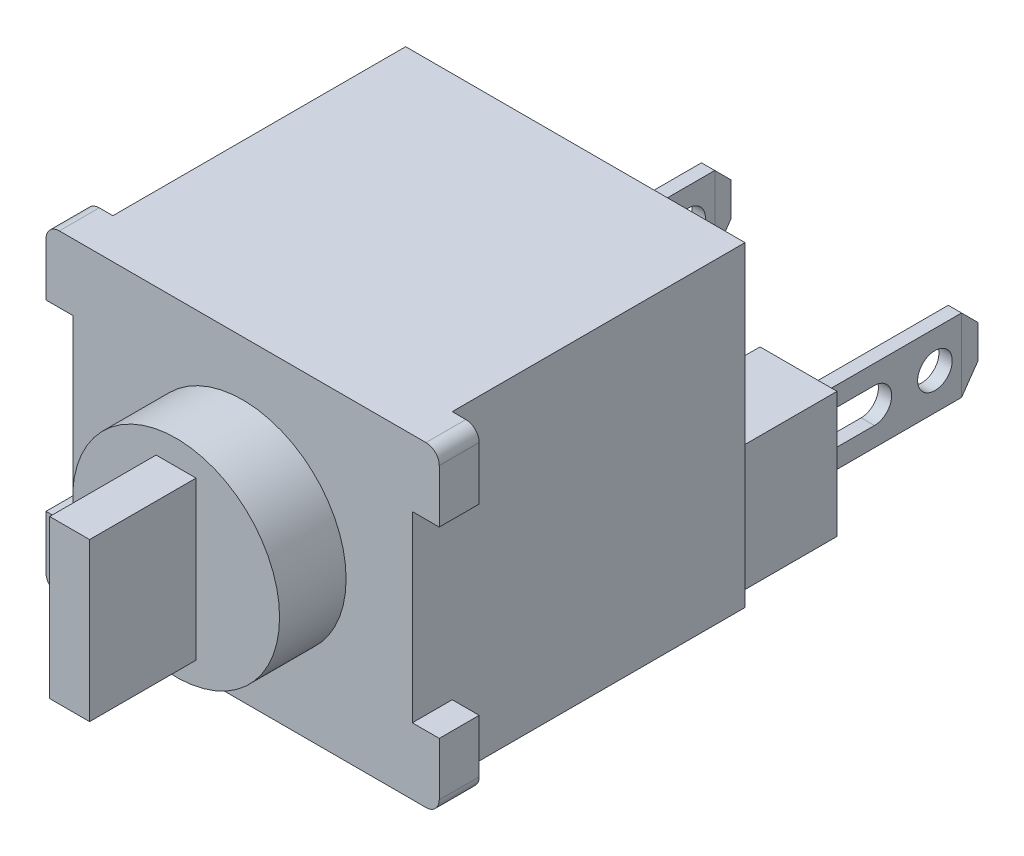
from build123d import *
from OCP.BRepFilletAPI import BRepFilletAPI_MakeChamfer

# Parameters (mm, degrees)
SKETCH1_W                          = 12.954
SKETCH1_H                          = 12.065
EXTRUDE1_DEPTH                     = 12.7
SKETCH2_W                          = 2.939197004
SKETCH2_H                          = 4.798107158
STANDOFF_DEPTH                     = 3.81
SKETCH3_W                          = 0.508
SKETCH3_H                          = 2.794
METAL_DEPTH                        = 6.731
WIRE_HOLE_REACH                    = 20.127
SKETCH4_R                          = 0.6604
CHAMFER1_SIZE                      = 0.762
CHAMFER2_SIZE                      = 0.762
CHAMFER2_SIZE2                     = 0.134361159
CHAMFER1_OF_CONNECTOR_MIRROR_SIZE  = 0.762
CHAMFER2_OF_CONNECTOR_MIRROR_SIZE  = 0.762
CHAMFER2_OF_CONNECTOR_MIRROR_SIZE2 = 0.134361159
SKETCH5_W                          = 1.0287
SKETCH5_H                          = 2.54
TABS_DEPTH                         = 1.524
FILLET1_R                          = 0.508
TEXT_2_DEPTH                       = 0.254
SKETCH7_R                          = 3.9497
PLUNGER_DEPTH                      = 2.54
SKETCH8_W                          = 1.524
SKETCH8_H                          = 6.0198
PLUNGER_I_DEPTH                    = 4.064


with BuildPart() as part:
    # Sketch1 → Extrude1 (new body)
    with BuildSketch(Plane.XY):
        Rectangle(SKETCH1_W, SKETCH1_H)
    extrude(amount=EXTRUDE1_DEPTH)

    # Sketch2 → standoff (add)
    with BuildSketch(Plane(origin=(0, 0, 0), x_dir=(-1, 0, 0), z_dir=(0, 0, -1))):
        with Locations((4.710259285, -3.336304208)):
            Rectangle(SKETCH2_W, SKETCH2_H)
    standoff = extrude(amount=STANDOFF_DEPTH)

    # Sketch3 → metal (add)
    with BuildSketch(Plane(origin=(0, 0, -3.81), x_dir=(-1, 0, 0), z_dir=(0, 0, -1))):
        with Locations((4.710259285, -3.336304208)):
            Rectangle(SKETCH3_W, SKETCH3_H)
    metal = extrude(amount=METAL_DEPTH)

    # Sketch4 → wire hole (cut, up to next)
    with BuildSketch(Plane.ZY.offset(4.964259285), mode=Mode.PRIVATE) as wire_hole_sk1:
        with Locations((-8.763, -3.336304208)):
            Circle(SKETCH4_R)
    wire_hole_tool1 = extrude(wire_hole_sk1.sketch, amount=-WIRE_HOLE_REACH, mode=Mode.PRIVATE) & part.part
    # Sketch4 → wire hole (cut, up to next)
    with BuildSketch(Plane.ZY.offset(4.964259285), mode=Mode.PRIVATE) as wire_hole_sk2:
        with BuildLine():
            Line((-4.4704, -3.996704208), (-6.4516, -3.996704208))
            ThreePointArc((-6.4516, -3.996704208), (-7.112, -3.336304208), (-6.4516, -2.675904208))
            Line((-6.4516, -2.675904208), (-4.4704, -2.675904208))
            ThreePointArc((-4.4704, -2.675904208), (-3.81, -3.336304208), (-4.4704, -3.996704208))
        make_face()
    wire_hole_tool2 = extrude(wire_hole_sk2.sketch, amount=-WIRE_HOLE_REACH, mode=Mode.PRIVATE) & part.part
    wire_hole_1 = wire_hole_tool1.solids().sort_by_distance((-4.964259, -3.336304, -8.763))[0]
    add(wire_hole_1, mode=Mode.SUBTRACT)
    wire_hole_2 = wire_hole_tool2.solids().sort_by_distance((-4.964259, -3.336304, -5.461))[0]
    add(wire_hole_2, mode=Mode.SUBTRACT)
    wire_hole = wire_hole_1 + wire_hole_2  # wire hole as one shape, for the pattern or mirror that repeats it

    # Chamfer1
    chamfer1_edges = [part.edges().sort_by_distance(p)[0] for p in [
        (-4.710259285, -1.939304208, -10.541),
        (-4.710259285, -4.733304208, -10.541),
    ]]
    chamfer(chamfer1_edges, length=CHAMFER1_SIZE)

    # Chamfer2: one chamfer whose edges measure the first distance from different faces: ONE call of the kernel's chamfer builder (chamfer() names one face for all edges)
    chamfer2_edges_1 = [part.edges().sort_by_distance(p)[0] for p in [
        (-4.456259285, -3.336304208, -10.541),
    ]]
    chamfer2_side_1 = [part.faces().sort_by_distance(p)[0] for p in [
        (-4.456259285, -3.336304208, -7.397261172),
    ]]
    chamfer2_edges_2 = [part.edges().sort_by_distance(p)[0] for p in [
        (-4.964259285, -3.336304208, -10.541),
    ]]
    chamfer2_side_2 = [part.faces().sort_by_distance(p)[0] for p in [
        (-4.964259285, -3.336304208, -7.397261172),
    ]]
    chamfer2 = BRepFilletAPI_MakeChamfer(part.part.solid().wrapped)
    for e in chamfer2_edges_1:
        chamfer2.Add(CHAMFER2_SIZE, CHAMFER2_SIZE2, e.wrapped, chamfer2_side_1[0].wrapped)  # the first distance lies on this face
    for e in chamfer2_edges_2:
        chamfer2.Add(CHAMFER2_SIZE, CHAMFER2_SIZE2, e.wrapped, chamfer2_side_2[0].wrapped)  # the first distance lies on this face
    add(Compound.cast(chamfer2.Shape()), mode=Mode.REPLACE)

    # connector mirror: standoff, metal, wire hole across plane
    add(standoff.mirror(Plane(origin=(0, 0, 0), x_dir=(0, 0, 1), z_dir=(1, 0, 0))))
    add(metal.mirror(Plane(origin=(0, 0, 0), x_dir=(0, 0, 1), z_dir=(1, 0, 0))))
    add(wire_hole.mirror(Plane(origin=(0, 0, 0), x_dir=(0, 0, 1), z_dir=(1, 0, 0))), mode=Mode.SUBTRACT)

    # Chamfer1 of connector mirror
    chamfer1_of_connector_mirror_edges = [part.edges().sort_by_distance(p)[0] for p in [
        (4.710259285, -1.939304208, -10.541),
        (4.710259285, -4.733304208, -10.541),
    ]]
    chamfer(chamfer1_of_connector_mirror_edges, length=CHAMFER1_OF_CONNECTOR_MIRROR_SIZE)

    # Chamfer2 of connector mirror: one chamfer whose edges measure the first distance from different faces: ONE call of the kernel's chamfer builder (chamfer() names one face for all edges)
    chamfer2_of_connector_mirror_edges_1 = [part.edges().sort_by_distance(p)[0] for p in [
        (4.456259285, -3.336304208, -10.541),
    ]]
    chamfer2_of_connector_mirror_side_1 = [part.faces().sort_by_distance(p)[0] for p in [
        (4.456259285, -3.336304208, -7.397261172),
    ]]
    chamfer2_of_connector_mirror_edges_2 = [part.edges().sort_by_distance(p)[0] for p in [
        (4.964259285, -3.336304208, -10.541),
    ]]
    chamfer2_of_connector_mirror_side_2 = [part.faces().sort_by_distance(p)[0] for p in [
        (4.964259285, -3.336304208, -7.397261172),
    ]]
    chamfer2_of_connector_mirror = BRepFilletAPI_MakeChamfer(part.part.solid().wrapped)
    for e in chamfer2_of_connector_mirror_edges_1:
        chamfer2_of_connector_mirror.Add(CHAMFER2_OF_CONNECTOR_MIRROR_SIZE, CHAMFER2_OF_CONNECTOR_MIRROR_SIZE2, e.wrapped, chamfer2_of_connector_mirror_side_1[0].wrapped)  # the first distance lies on this face
    for e in chamfer2_of_connector_mirror_edges_2:
        chamfer2_of_connector_mirror.Add(CHAMFER2_OF_CONNECTOR_MIRROR_SIZE, CHAMFER2_OF_CONNECTOR_MIRROR_SIZE2, e.wrapped, chamfer2_of_connector_mirror_side_2[0].wrapped)  # the first distance lies on this face
    add(Compound.cast(chamfer2_of_connector_mirror.Shape()), mode=Mode.REPLACE)

    # Sketch5 → tabs (add)
    with BuildSketch(Plane.XY.offset(12.7)):
        with Locations((6.99135, -4.7625)):
            Rectangle(SKETCH5_W, SKETCH5_H)
        with Locations((6.99135, 4.7625)):
            Rectangle(SKETCH5_W, SKETCH5_H)
        with Locations((-6.99135, 4.7625)):
            Rectangle(SKETCH5_W, SKETCH5_H)
        with Locations((-6.99135, -4.7625)):
            Rectangle(SKETCH5_W, SKETCH5_H)
    extrude(amount=-TABS_DEPTH)

    # Fillet1
    fillet1_edges = [part.edges().sort_by_distance(p)[0] for p in [
        (-7.5057, -6.0325, 11.938),
        (-7.5057, 6.0325, 11.938),
        (7.5057, 6.0325, 11.938),
        (7.5057, -6.0325, 11.938),
    ]]
    fillet(fillet1_edges, radius=FILLET1_R)

    # Sketch6 → text 2 (add)
    with BuildSketch(Plane(origin=(0, 0, 0), x_dir=(-1, 0, 0), z_dir=(0, 0, -1))):
        with BuildLine():
            Line((-5.383171322, 1.004934785), (-5.211395681, 1.10791876))
            add(Edge.make_bspline(
                [(-5.211395681, 1.10791876), (-5.195419379, 1.081175094), (-5.1648094, 1.029935262), (-5.113747354, 0.960697451), (-5.060838189, 0.901849479), (-5.005690096, 0.853733689), (-4.948639694, 0.815852049), (-4.889314552, 0.789028354), (-4.827914589, 0.772298622), (-4.786128645, 0.770266572), (-4.765267476, 0.769252093)],
                knots=[0, 0, 0, 0, 1.272034388, 2.437168799, 3.508375237, 4.49857839, 5.41946034, 6.295179144, 7.148887113, 8, 8, 8, 8], degree=3))
            add(Edge.make_bspline(
                [(-4.765267476, 0.769252093), (-4.747451561, 0.769748291), (-4.712131469, 0.770732006), (-4.66013419, 0.780184175), (-4.609635041, 0.794705502), (-4.561674826, 0.815502111), (-4.516915315, 0.840663198), (-4.477664799, 0.871053893), (-4.443732656, 0.905078981), (-4.41597605, 0.943038283), (-4.394680669, 0.98386241), (-4.37831316, 1.025765705), (-4.369230077, 1.069406428), (-4.367861813, 1.098789417), (-4.367171322, 1.113617478)],
                knots=[0, 0, 0, 0, 1.095163259, 2.171163733, 3.241058638, 4.321873601, 5.38011039, 6.391990106, 7.366004449, 8.327778327, 9.272591725, 10.192022065, 11.087607919, 12, 12, 12, 12], degree=3))
            add(Edge.make_bspline(
                [(-4.367171322, 1.113617478), (-4.368027265, 1.130535822), (-4.369767271, 1.164928345), (-4.384474005, 1.215670086), (-4.407609339, 1.265885201), (-4.428952679, 1.296946507), (-4.440033501, 1.313072606)],
                knots=[0, 0, 0, 0, 0.938893495, 1.908633276, 2.914225137, 4, 4, 4, 4], degree=3))
            add(Edge.make_bspline(
                [(-4.440033501, 1.313072606), (-4.449131412, 1.324711219), (-4.468231338, 1.349145031), (-4.501067014, 1.385515065), (-4.539597284, 1.423030673), (-4.582503576, 1.463124388), (-4.631348844, 1.503931475), (-4.684603218, 1.547397858), (-4.74362635, 1.591870545), (-4.7850208, 1.621695988), (-4.806379655, 1.637085426)],
                knots=[0, 0, 0, 0, 0.722233717, 1.516239348, 2.393582979, 3.351407094, 4.387010283, 5.505090956, 6.712668013, 8, 8, 8, 8], degree=3))
            add(Edge.make_bspline(
                [(-4.806379655, 1.637085426), (-4.827758615, 1.652312995), (-4.868633559, 1.681426946), (-4.925795799, 1.724635559), (-4.976911899, 1.764139886), (-5.021754665, 1.800311815), (-5.060304373, 1.833156253), (-5.0928648, 1.8623578), (-5.118606499, 1.888706198), (-5.132920825, 1.905799), (-5.139347604, 1.913473247)],
                knots=[0, 0, 0, 0, 1.452282411, 2.77665338, 3.964542531, 5.026858415, 5.96415736, 6.766646006, 7.446254459, 8, 8, 8, 8], degree=3))
            add(Edge.make_bspline(
                [(-5.139347604, 1.913473247), (-5.148330522, 1.92543362), (-5.165996635, 1.9489553), (-5.18931587, 1.985719903), (-5.209136093, 2.023354439), (-5.224673538, 2.061960038), (-5.237757423, 2.100994716), (-5.246557684, 2.140967782), (-5.252068118, 2.181699872), (-5.252632426, 2.209110681), (-5.252914912, 2.222832221)],
                knots=[0, 0, 0, 0, 1.068054152, 2.10047183, 3.106115577, 4.101338837, 5.06977816, 6.043150881, 7.020423561, 8, 8, 8, 8], degree=3))
            add(Edge.make_bspline(
                [(-5.252914912, 2.222832221), (-5.252157145, 2.24433065), (-5.250657807, 2.286867995), (-5.237977827, 2.349007037), (-5.21796385, 2.408333551), (-5.189925218, 2.464260191), (-5.153780378, 2.515330726), (-5.111952543, 2.562132613), (-5.062132846, 2.601477116), (-5.007470523, 2.635853945), (-4.947638938, 2.662761065), (-4.884942505, 2.683058411), (-4.819281576, 2.6945591), (-4.774807985, 2.696209528), (-4.752241835, 2.697046965)],
                knots=[0, 0, 0, 0, 1.005424448, 1.989358655, 2.955360095, 3.929531133, 4.905563448, 5.876582895, 6.856512386, 7.866279853, 8.892233794, 9.918561126, 10.94386622, 12, 12, 12, 12], degree=3))
            add(Edge.make_bspline(
                [(-4.752241835, 2.697046965), (-4.728296689, 2.696221072), (-4.680677435, 2.694578635), (-4.610631948, 2.680298011), (-4.543192355, 2.656668364), (-4.488941865, 2.629852549), (-4.446483073, 2.603069967), (-4.414103018, 2.578674457), (-4.381290601, 2.550589251), (-4.347781147, 2.51873954), (-4.314142456, 2.482833084), (-4.279875126, 2.443115792), (-4.244899025, 2.399830386), (-4.22239848, 2.368929762), (-4.21086363, 2.353088631)],
                knots=[0, 0, 0, 0, 1.286793592, 2.559021753, 3.825965368, 5.121522368, 5.803751409, 6.523245864, 7.299691795, 8.125521123, 9.008227632, 9.944561021, 10.946284179, 12, 12, 12, 12], degree=3))
            Line((-4.21086363, 2.353088631), (-4.375719399, 2.228123888))
            add(Edge.make_bspline(
                [(-4.375719399, 2.228123888), (-4.385673837, 2.24094795), (-4.404843759, 2.265644097), (-4.433947506, 2.3002295), (-4.461378721, 2.331822154), (-4.488404553, 2.359262936), (-4.513597656, 2.384054575), (-4.538049607, 2.405280125), (-4.561408522, 2.423147557), (-4.590853312, 2.442215589), (-4.627845998, 2.461116965), (-4.674282735, 2.477111173), (-4.722810538, 2.486722569), (-4.755862255, 2.487993374), (-4.772594399, 2.488636708)],
                knots=[0, 0, 0, 0, 1.181633172, 2.275549214, 3.290209073, 4.226197932, 5.078386478, 5.862611352, 6.581680152, 7.217281963, 8.414376989, 9.595101626, 10.782541182, 12, 12, 12, 12], degree=3))
            add(Edge.make_bspline(
                [(-4.772594399, 2.488636708), (-4.793585843, 2.48793323), (-4.834065865, 2.486576638), (-4.891536768, 2.471760464), (-4.943262155, 2.448432024), (-4.987706387, 2.415737157), (-5.024710255, 2.377000855), (-5.051477767, 2.332425245), (-5.06758872, 2.283203004), (-5.069554697, 2.248867048), (-5.070555937, 2.231380298)],
                knots=[0, 0, 0, 0, 1.14458467, 2.207223713, 3.21896685, 4.227309161, 5.202851033, 6.127160689, 7.046193047, 8, 8, 8, 8], degree=3))
            add(Edge.make_bspline(
                [(-5.070555937, 2.231380298), (-5.070327699, 2.220493725), (-5.06987085, 2.198702778), (-5.063499196, 2.166509267), (-5.055313528, 2.134397084), (-5.042342035, 2.102510601), (-5.024434133, 2.070292162), (-5.000917985, 2.03718697), (-4.971301113, 2.002903236), (-4.948614117, 1.980605012), (-4.936636066, 1.968832221)],
                knots=[0, 0, 0, 0, 0.858281714, 1.717966888, 2.583508476, 3.4729293, 4.427298488, 5.488583878, 6.674047936, 8, 8, 8, 8], degree=3))
            add(Edge.make_bspline(
                [(-4.936636066, 1.968832221), (-4.932188092, 1.964862839), (-4.921620724, 1.955432497), (-4.902301672, 1.939993778), (-4.876789739, 1.920949426), (-4.845751112, 1.89738559), (-4.80861349, 1.870051438), (-4.765372787, 1.839296472), (-4.716511006, 1.804122286), (-4.681838168, 1.779530708), (-4.663504655, 1.766527734)],
                knots=[0, 0, 0, 0, 0.420754252, 0.999615792, 1.744751191, 2.668019286, 3.750313428, 4.999500688, 6.413464383, 8, 8, 8, 8], degree=3))
            add(Edge.make_bspline(
                [(-4.663504655, 1.766527734), (-4.641451119, 1.75047995), (-4.598747504, 1.719405642), (-4.537986303, 1.672718595), (-4.482893669, 1.627057948), (-4.433276175, 1.582715292), (-4.388643638, 1.540026982), (-4.349491225, 1.498479444), (-4.315419995, 1.458370334), (-4.278739946, 1.406947627), (-4.241259521, 1.343792438), (-4.209071766, 1.2664149), (-4.188775948, 1.18873658), (-4.186121857, 1.136527628), (-4.184812348, 1.110768119)],
                knots=[0, 0, 0, 0, 1.163667725, 2.253281268, 3.268753668, 4.215851969, 5.092017293, 5.902905408, 6.650798638, 7.335211899, 8.59617414, 9.77448103, 10.901945474, 12, 12, 12, 12], degree=3))
            add(Edge.make_bspline(
                [(-4.184812348, 1.110768119), (-4.185193863, 1.092550736), (-4.185949486, 1.056469741), (-4.194635365, 1.003489651), (-4.207361296, 0.9520331), (-4.22654177, 0.902736134), (-4.249952244, 0.854696889), (-4.279657905, 0.809175502), (-4.314090253, 0.765164473), (-4.353588713, 0.723837372), (-4.396809877, 0.685899238), (-4.442491382, 0.652151165), (-4.490707997, 0.624011842), (-4.541198156, 0.601049753), (-4.593973455, 0.583090636), (-4.649016146, 0.570078365), (-4.706416959, 0.562092192), (-4.745431639, 0.561263275), (-4.765267476, 0.560841837)],
                knots=[0, 0, 0, 0, 0.983748083, 1.948392443, 2.894712957, 3.844097841, 4.80183111, 5.778335162, 6.776009319, 7.81870978, 8.863265674, 9.881300176, 10.883814829, 11.87499822, 12.874611388, 13.892143829, 14.928324115, 16, 16, 16, 16], degree=3))
            add(Edge.make_bspline(
                [(-4.765267476, 0.560841837), (-4.780615081, 0.561138614), (-4.811117003, 0.561728431), (-4.856232908, 0.566942706), (-4.900437378, 0.574320087), (-4.943175727, 0.586032576), (-4.98499859, 0.600243209), (-5.02572407, 0.617740664), (-5.065371905, 0.63870928), (-5.104164284, 0.662683991), (-5.142002548, 0.690584944), (-5.178531793, 0.723081557), (-5.214950566, 0.759277576), (-5.250183935, 0.800155937), (-5.284944572, 0.845056219), (-5.318547122, 0.89439851), (-5.351687137, 0.947914048), (-5.372480574, 0.985572864), (-5.383171322, 1.004934785)],
                knots=[0, 0, 0, 0, 0.915332311, 1.819136955, 2.706846663, 3.586547465, 4.459518054, 5.340707479, 6.227863349, 7.133153174, 8.059268498, 9.028702269, 10.047606654, 11.120612155, 12.245963614, 13.433783089, 14.680604001, 16, 16, 16, 16], degree=3))
        make_face()
        Polygon((-2.934350809, 2.644944401), (-1.996504655, 0.612944401), (-2.19473863, 0.612944401), (-2.495142476, 1.264226452), (-3.416299527, 1.264226452), (-3.72525145, 0.612944401), (-3.924299527, 0.612944401), (-2.960402091, 2.644944401), align=None)
        Polygon((-2.949411707, 2.248883503), (-3.317386066, 1.472636708), (-2.591206578, 1.472636708), align=None, mode=Mode.SUBTRACT)
        Polygon((-1.631786707, 0.612944401), (-1.631786707, 2.644944401), (-1.593523886, 2.644944401), (-0.251068758, 1.045639913), (-0.251068758, 2.644944401), (-0.068709784, 2.644944401), (-0.068709784, 0.612944401), (-0.110229014, 0.612944401), (-1.449427732, 2.208585426), (-1.449427732, 0.612944401), align=None)
        Polygon((0.322059447, 2.644944401), (0.510524191, 2.644944401), (0.908213293, 1.154729657), (1.499658806, 2.644944401), (1.52611714, 2.644944401), (2.106572268, 1.164905939), (2.506296627, 2.644944401), (2.692726114, 2.644944401), (2.144835088, 0.612944401), (2.118783806, 0.612944401), (1.507392781, 2.167066196), (0.888674832, 0.612944401), (0.86262355, 0.612944401), align=None)
        Polygon((3.891085088, 2.644944401), (4.828931242, 0.612944401), (4.630697268, 0.612944401), (4.330293422, 1.264226452), (3.40913637, 1.264226452), (3.100184447, 0.612944401), (2.90113637, 0.612944401), (3.865033806, 2.644944401), align=None)
        Polygon((3.876024191, 2.248883503), (3.508049832, 1.472636708), (4.234229319, 1.472636708), align=None, mode=Mode.SUBTRACT)
    extrude(amount=TEXT_2_DEPTH)

    # Sketch7 → plunger (add)
    with BuildSketch(Plane.XY.offset(12.7)):
        Circle(SKETCH7_R)
    extrude(amount=PLUNGER_DEPTH)

    # Sketch8 → plunger I (add)
    with BuildSketch(Plane.XY.offset(15.24)):
        Rectangle(SKETCH8_W, SKETCH8_H)
    extrude(amount=PLUNGER_I_DEPTH)


solid = part.part
